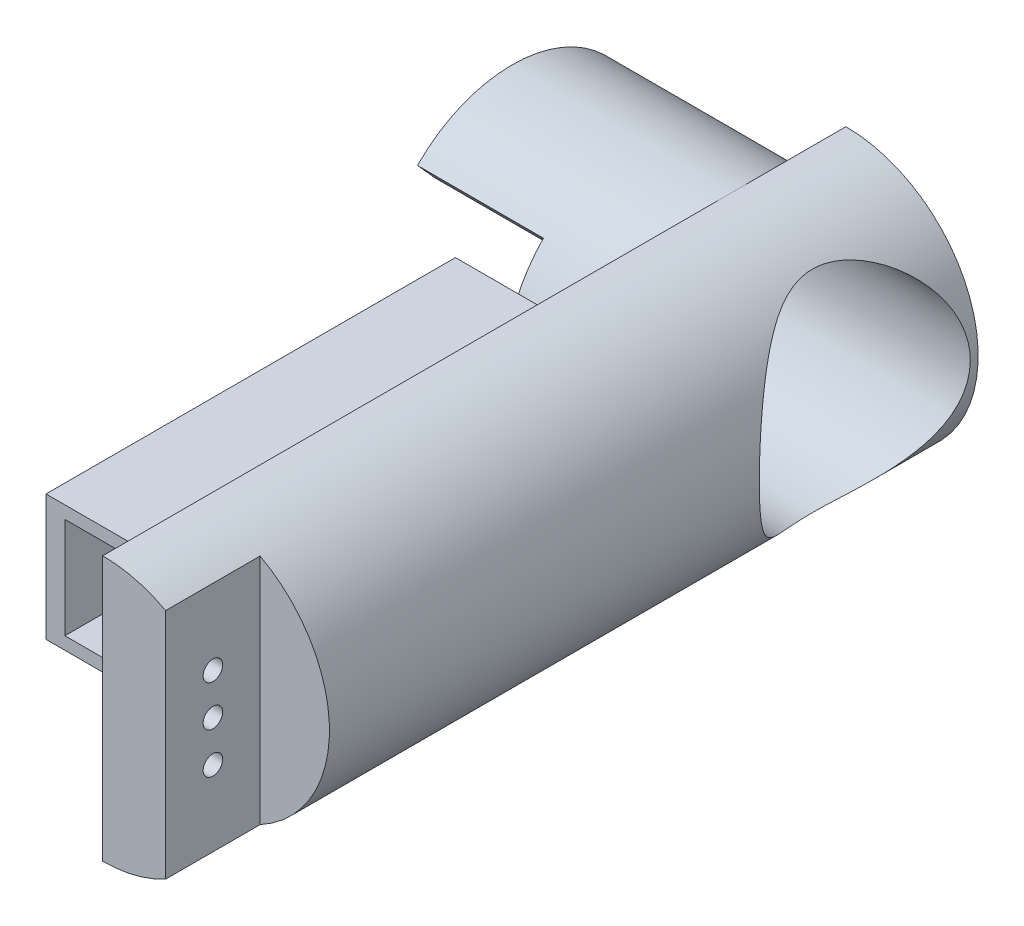
from build123d import *

# Parameters (mm, degrees)
SKETCH1_R                = 21
BOSS_EXTRUDE1_DEPTH      = 35
BOSS_EXTRUDE2_DEPTH      = 100
BOSS_EXTRUDE2_DEPTH_BACK = 18
CUT_EXTRUDE2_DEPTH       = 15
SKETCH7_W                = 9
SKETCH7_H                = 30
CUT_EXTRUDE3_DEPTH       = 7
SKETCH8_R                = 1.55
CUT_EXTRUDE4_DEPTH       = 7
SKETCH9_R                = 16.75
CUT_EXTRUDE5_DEPTH       = 20
CUT_EXTRUDE6_DEPTH       = 20
SKETCH11_R               = 1.65
CUT_EXTRUDE9_DEPTH       = 25
SKETCH12_R               = 16.75
CUT_EXTRUDE8_DEPTH       = 10
CUT_EXTRUDE8_DEPTH_BACK  = 25
CUT_EXTRUDE10_DEPTH      = 20
SKETCH15_W               = 65
SKETCH15_H               = 20
BOSS_EXTRUDE3_DEPTH      = 24
SKETCH16_W               = 13
SKETCH16_H               = 16
CUT_EXTRUDE11_DEPTH      = 65


with BuildPart() as part:
    # Sketch1 → Boss-Extrude1 (new body)
    with BuildSketch(Plane(origin=(0, 0, 0), x_dir=(0, 0, -1), z_dir=(1, 0, 0))):
        Circle(SKETCH1_R)
    extrude(amount=BOSS_EXTRUDE1_DEPTH)

    # Sketch4 → Boss-Extrude2 (add, two sides)
    with BuildSketch(Plane.XY) as boss_extrude2_sk:
        with BuildLine():
            Line((35, 21), (35, -21))
            ThreePointArc((35, -21), (56, 0), (35, 21))
        make_face()
    extrude(amount=BOSS_EXTRUDE2_DEPTH)
    extrude(boss_extrude2_sk.sketch, amount=-BOSS_EXTRUDE2_DEPTH_BACK)

    # Sketch5 → Cut-Extrude2 (cut)
    with BuildSketch(Plane.XY.offset(100)):
        with BuildLine():
            Line((45, -18.466185313), (45, 18.466185313))
            ThreePointArc((45, 18.466185313), (56, 0), (45, -18.466185313))
        make_face()
    extrude(amount=-CUT_EXTRUDE2_DEPTH, mode=Mode.SUBTRACT)

    # Sketch7 → Cut-Extrude3 (cut)
    with BuildSketch(Plane.ZY.offset(-35)):
        with Locations((92.5, 0)):
            Rectangle(SKETCH7_W, SKETCH7_H)
    extrude(amount=-CUT_EXTRUDE3_DEPTH, mode=Mode.SUBTRACT)

    # Sketch8 → Cut-Extrude4 (cut)
    with BuildSketch(Plane.ZY.offset(-42)):
        with Locations((92.5, 6.5)):
            Circle(SKETCH8_R)
        with Locations((92.5, 0)):
            Circle(SKETCH8_R)
        with Locations((92.5, -6.5)):
            Circle(SKETCH8_R)
    extrude(amount=-CUT_EXTRUDE4_DEPTH, mode=Mode.SUBTRACT)

    # Sketch9 → Cut-Extrude5 (cut)
    with BuildSketch(Plane.ZY):
        Circle(SKETCH9_R)
    extrude(amount=-CUT_EXTRUDE5_DEPTH, mode=Mode.SUBTRACT)

    # Sketch10 → Cut-Extrude6 (cut)
    with BuildSketch(Plane.ZY):
        with BuildLine():
            Line((15.02133973, 14.675127009), (12.173811363, 11.504817117))
            ThreePointArc((12.173811363, 11.504817117), (16.743318767, -0.473050368), (11.504817117, -12.173811363))
            Line((11.504817117, -12.173811363), (14.675127009, -15.02133973))
            ThreePointArc((14.675127009, -15.02133973), (20.998573008, -0.244809363), (15.02133973, 14.675127009))
        make_face()
    extrude(amount=-CUT_EXTRUDE6_DEPTH, mode=Mode.SUBTRACT)

    # Sketch11 → Cut-Extrude9 (cut)
    with BuildSketch(Plane.ZY.offset(-20)):
        with Locations((-8.485281374, 8.485281374)):
            Circle(SKETCH11_R)
        with Locations((8.485281374, 8.485281374)):
            Circle(SKETCH11_R)
        with Locations((8.485281374, -8.485281374)):
            Circle(SKETCH11_R)
        with Locations((-8.485281374, -8.485281374)):
            Circle(SKETCH11_R)
    extrude(amount=-CUT_EXTRUDE9_DEPTH, mode=Mode.SUBTRACT)

    # Sketch12 → Cut-Extrude8 (cut, two sides)
    with BuildSketch(Plane.ZY.offset(-35)) as cut_extrude8_sk:
        Circle(SKETCH12_R)
    extrude(amount=CUT_EXTRUDE8_DEPTH, mode=Mode.SUBTRACT)
    extrude(cut_extrude8_sk.sketch, amount=-CUT_EXTRUDE8_DEPTH_BACK, mode=Mode.SUBTRACT)

    # Sketch14 → Cut-Extrude10 (cut)
    with BuildSketch(Plane.ZY):
        with BuildLine():
            Line((-14.710965935, 14.986243067), (-11.829145313, 11.858913153))
            ThreePointArc((-11.829145313, 11.858913153), (-16.749986774, 0.021049042), (-11.858913153, -11.829145313))
            Line((-11.858913153, -11.829145313), (-14.986243067, -14.710965935))
            ThreePointArc((-14.986243067, -14.710965935), (-20.999097868, 0.194650327), (-14.710965935, 14.986243067))
        make_face()
    extrude(amount=-CUT_EXTRUDE10_DEPTH, mode=Mode.SUBTRACT)

    # Sketch15 → Boss-Extrude3 (add)
    with BuildSketch(Plane.ZY.offset(-35)):
        with Locations((52.5, 0)):
            Rectangle(SKETCH15_W, SKETCH15_H)
    extrude(amount=BOSS_EXTRUDE3_DEPTH)

    # Sketch16 → Cut-Extrude11 (cut)
    with BuildSketch(Plane.XY.offset(85)):
        with Locations((20.5, 0)):
            Rectangle(SKETCH16_W, SKETCH16_H)
    extrude(amount=-CUT_EXTRUDE11_DEPTH, mode=Mode.SUBTRACT)


solid = part.part
